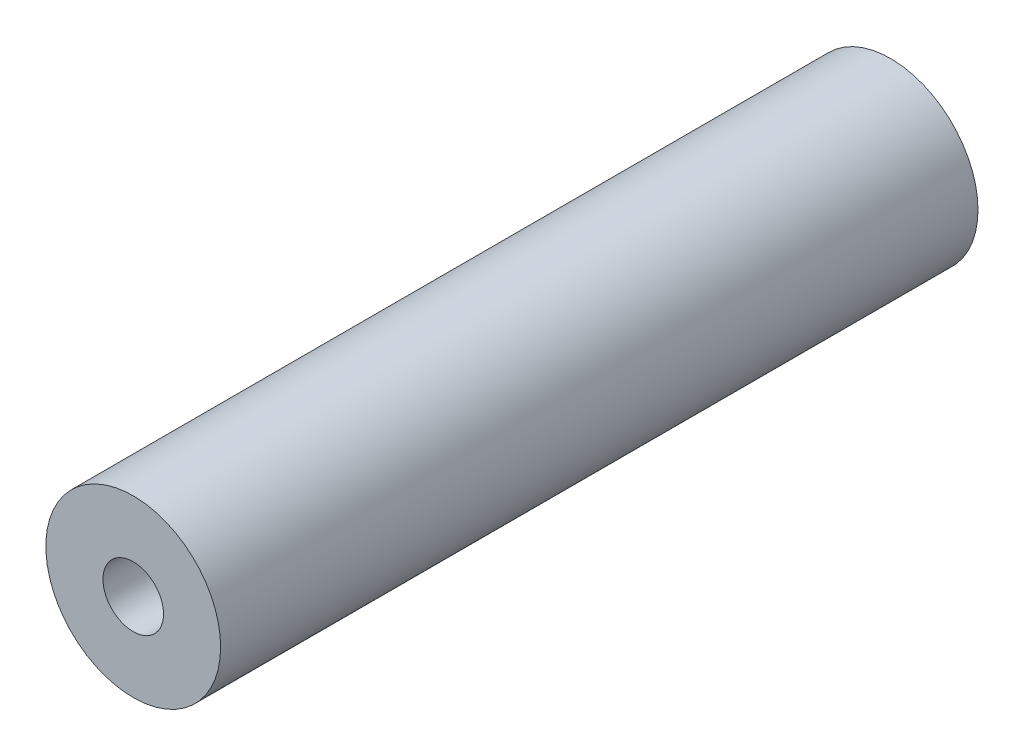
from build123d import *

# Parameters (mm, degrees)
SKETCH1_R                 = 4.7625
BOSS_EXTRUDE1_DEPTH       = 41.275
M4X0_7_TAPPED_HOLE1_D     = 3.3
M4X0_7_TAPPED_HOLE1_DEPTH = 12.7
M4X0_7_TAPPED_HOLE1_TIP   = 0.991420021
F_8_32_TAPPED_HOLE1_D     = 3.4544
F_8_32_TAPPED_HOLE1_DEPTH = 13.208
F_8_32_TAPPED_HOLE1_TIP   = 1.037806461


with BuildPart() as part:
    # Sketch1 → Boss-Extrude1 (new body)
    with BuildSketch(Plane.XY):
        Circle(SKETCH1_R)
    extrude(amount=BOSS_EXTRUDE1_DEPTH)

    # M4x0.7 Tapped Hole1
    with Locations(Plane.XY.offset(41.275)):
        with Locations((0, 0)):
            Hole(M4X0_7_TAPPED_HOLE1_D / 2, depth=M4X0_7_TAPPED_HOLE1_DEPTH)
            with Locations((0, 0, -(M4X0_7_TAPPED_HOLE1_DEPTH + M4X0_7_TAPPED_HOLE1_TIP / 2))):  # 118° drill point
                Cone(0, M4X0_7_TAPPED_HOLE1_D / 2, M4X0_7_TAPPED_HOLE1_TIP, mode=Mode.SUBTRACT)

    # #8-32 Tapped Hole1
    with Locations(Plane(origin=(0, 0, 0), x_dir=(-1, 0, 0), z_dir=(0, 0, -1))):
        with Locations((0, 0)):
            Hole(F_8_32_TAPPED_HOLE1_D / 2, depth=F_8_32_TAPPED_HOLE1_DEPTH)
            with Locations((0, 0, -(F_8_32_TAPPED_HOLE1_DEPTH + F_8_32_TAPPED_HOLE1_TIP / 2))):  # 118° drill point
                Cone(0, F_8_32_TAPPED_HOLE1_D / 2, F_8_32_TAPPED_HOLE1_TIP, mode=Mode.SUBTRACT)


solid = part.part
